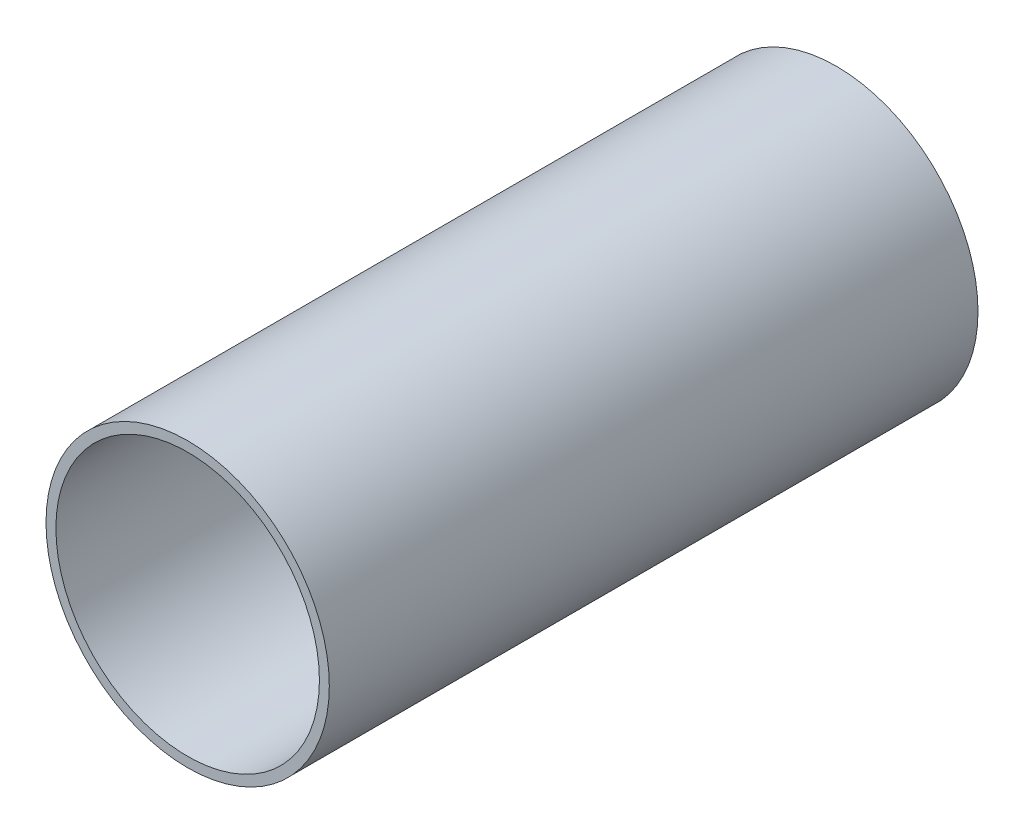
from build123d import *

# Parameters (mm, degrees)
SKETCH1_R           = 22.1869
SKETCH1_R_2         = 20.6375
BOSS_EXTRUDE1_DEPTH = 101.6


with BuildPart() as part:
    # Sketch1 → Boss-Extrude1 (new body)
    with BuildSketch(Plane.XY):
        Circle(SKETCH1_R)
        Circle(SKETCH1_R_2, mode=Mode.SUBTRACT)
    extrude(amount=BOSS_EXTRUDE1_DEPTH)


solid = part.part
